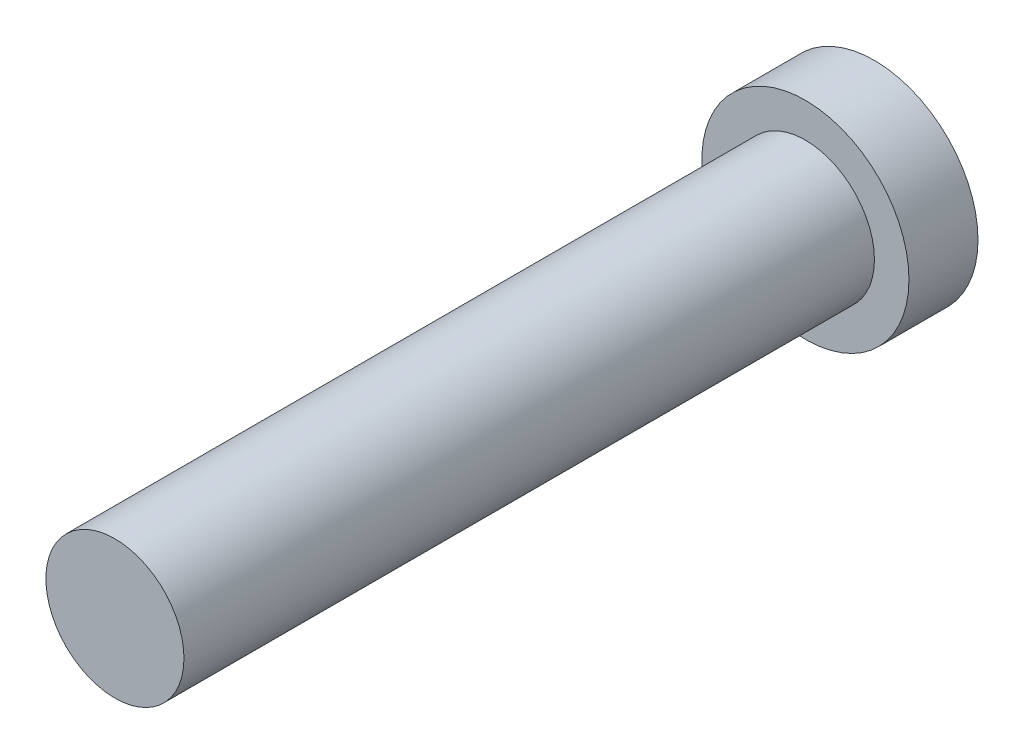
from build123d import *

# Parameters (mm, degrees)
SKETCH1_R           = 3.81
BOSS_EXTRUDE1_DEPTH = 2.54
SKETCH2_R           = 2.54
BOSS_EXTRUDE2_DEPTH = 25.4


with BuildPart() as part:
    # Sketch1 → Boss-Extrude1 (new body)
    with BuildSketch(Plane.XY):
        Circle(SKETCH1_R)
    extrude(amount=BOSS_EXTRUDE1_DEPTH)

    # Sketch2 → Boss-Extrude2 (add)
    with BuildSketch(Plane.XY.offset(2.54)):
        Circle(SKETCH2_R)
    extrude(amount=BOSS_EXTRUDE2_DEPTH)


solid = part.part
